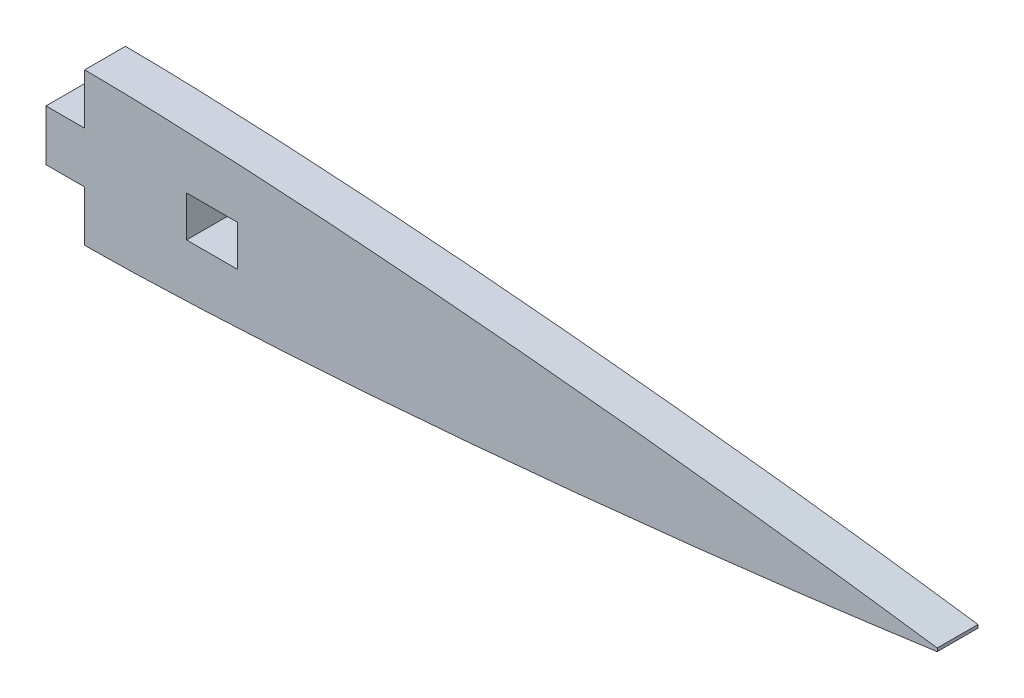
from build123d import *

# Parameters (mm, degrees)
BOSS_EXTRUDE1_DEPTH = 5.08
SKETCH3_W           = 4.826
SKETCH3_H           = 6.35076331
SKETCH3_W_2         = 6.35
SKETCH3_H_2         = 5.08
CUT_EXTRUDE1_DEPTH  = 6.0800001


with BuildPart() as part:
    # Sketch2 → Boss-Extrude1 (new body)
    with BuildSketch(Plane.XY):
        with BuildLine():
            Line((158.75, -0.200025), (158.75, 0.200025))
            add(Edge.make_bspline(
                [(158.75, 0.200025), (156.104769639, 0.564899501), (150.817056987, 1.294269442), (142.878358215, 2.306719234), (134.940769513, 3.268408227), (127.002836924, 4.172206586), (119.065195908, 5.02492376), (111.127662782, 5.825402282), (103.190287717, 6.571495389), (95.252619427, 7.253962327), (87.315238521, 7.873917198), (79.324754405, 8.420599463), (71.334509538, 8.88842609), (63.343416227, 9.23480821), (55.458296632, 9.48903948), (50.217735657, 9.487192482), (47.625, 9.52576331)],
                knots=[0, 0, 0, 0, 0.024634231, 0.04924287, 0.07382978, 0.098396751, 0.122945996, 0.147478562, 0.171994581, 0.196493552, 0.220976186, 0.245442093, 0.270380478, 0.294812969, 0.319231823, 0.343153728, 0.343153728, 0.343153728, 0.343153728], degree=3))
            Line((47.625, 9.52576331), (47.625, -9.52576331))
            add(Edge.make_bspline(
                [(47.625, -9.52576331), (50.217735657, -9.487192482), (55.458296632, -9.48903948), (63.343416227, -9.23480821), (71.334509538, -8.88842609), (79.324754405, -8.420599463), (87.315238521, -7.873917198), (95.252619427, -7.253962327), (103.190287717, -6.571495389), (111.127662782, -5.825402282), (119.065195908, -5.02492376), (127.002836924, -4.172206586), (134.940769513, -3.268408227), (142.878358215, -2.306719234), (150.817056987, -1.294269442), (156.104769639, -0.564899501), (158.75, -0.200025)],
                knots=[0.656846272, 0.656846272, 0.656846272, 0.656846272, 0.680768177, 0.705187031, 0.729619522, 0.754557907, 0.779023814, 0.803506448, 0.828005419, 0.852521438, 0.877054004, 0.901603249, 0.92617022, 0.95075713, 0.975365769, 1, 1, 1, 1], degree=3))
        make_face()
    extrude(amount=BOSS_EXTRUDE1_DEPTH)

    # Sketch3 → Cut-Extrude1 (cut, through all)
    with BuildSketch(Plane(origin=(0, 0, 0), x_dir=(-1, 0, 0), z_dir=(0, 0, -1))):
        with Locations((-50.038, -6.350381655)):
            Rectangle(SKETCH3_W, SKETCH3_H)
        with Locations((-50.038, 6.350381655)):
            Rectangle(SKETCH3_W, SKETCH3_H)
        with Locations((-68.326, 0)):
            Rectangle(SKETCH3_W_2, SKETCH3_H_2)
    extrude(amount=-CUT_EXTRUDE1_DEPTH, mode=Mode.SUBTRACT)


solid = part.part
